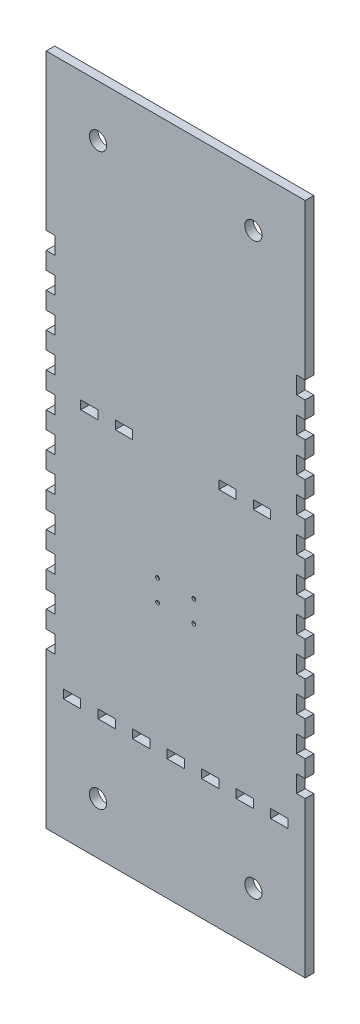
from build123d import *

# Parameters (mm, degrees)
CROQUIS1_W              = 150
CROQUIS1_H              = 390
CROQUIS1_R              = 5
SALIENTE_EXTRUIR1_DEPTH = 5
CROQUIS3_W              = 5
CROQUIS3_H              = 10
CROQUIS3_W_2            = 10
CROQUIS3_H_2            = 5
CORTAR_EXTRUIR1_DEPTH   = 10
CROQUIS4_W              = 10
CROQUIS4_H              = 5
CORTAR_EXTRUIR2_DEPTH   = 10
CROQUIS6_R              = 1.1
CORTAR_EXTRUIR7_DEPTH   = 1


with BuildPart() as part:
    # Croquis1 → Saliente-Extruir1 (new body)
    with BuildSketch(Plane.XY):
        Rectangle(CROQUIS1_W, CROQUIS1_H)
        with Locations((-45, 165)):
            Circle(CROQUIS1_R, mode=Mode.SUBTRACT)
        with Locations((45, 165)):
            Circle(CROQUIS1_R, mode=Mode.SUBTRACT)
        with Locations((-45, -165)):
            Circle(CROQUIS1_R, mode=Mode.SUBTRACT)
        with Locations((45, -165)):
            Circle(CROQUIS1_R, mode=Mode.SUBTRACT)
    extrude(amount=SALIENTE_EXTRUIR1_DEPTH)

    # Croquis3 → Cortar-Extruir1 (cut)
    with BuildSketch(Plane(origin=(0, 0, 0), x_dir=(-1, 0, 0), z_dir=(0, 0, -1))):
        with Locations((-72.5, 100)):
            Rectangle(CROQUIS3_W, CROQUIS3_H)
        with Locations((-72.5, 80)):
            Rectangle(CROQUIS3_W, CROQUIS3_H)
        with Locations((-72.5, 60)):
            Rectangle(CROQUIS3_W, CROQUIS3_H)
        with Locations((-72.5, 40)):
            Rectangle(CROQUIS3_W, CROQUIS3_H)
        with Locations((-72.5, 20)):
            Rectangle(CROQUIS3_W, CROQUIS3_H)
        with Locations((-72.5, 0)):
            Rectangle(CROQUIS3_W, CROQUIS3_H)
        with Locations((-72.5, -20)):
            Rectangle(CROQUIS3_W, CROQUIS3_H)
        with Locations((-72.5, -40)):
            Rectangle(CROQUIS3_W, CROQUIS3_H)
        with Locations((-72.5, -60)):
            Rectangle(CROQUIS3_W, CROQUIS3_H)
        with Locations((-72.5, -80)):
            Rectangle(CROQUIS3_W, CROQUIS3_H)
        with Locations((-72.5, -100)):
            Rectangle(CROQUIS3_W, CROQUIS3_H)
        with Locations((72.5, -100)):
            Rectangle(CROQUIS3_W, CROQUIS3_H)
        with Locations((72.5, -80)):
            Rectangle(CROQUIS3_W, CROQUIS3_H)
        with Locations((72.5, -60)):
            Rectangle(CROQUIS3_W, CROQUIS3_H)
        with Locations((72.5, -40)):
            Rectangle(CROQUIS3_W, CROQUIS3_H)
        with Locations((72.5, -20)):
            Rectangle(CROQUIS3_W, CROQUIS3_H)
        with Locations((72.5, 0)):
            Rectangle(CROQUIS3_W, CROQUIS3_H)
        with Locations((72.5, 20)):
            Rectangle(CROQUIS3_W, CROQUIS3_H)
        with Locations((72.5, 40)):
            Rectangle(CROQUIS3_W, CROQUIS3_H)
        with Locations((72.5, 60)):
            Rectangle(CROQUIS3_W, CROQUIS3_H)
        with Locations((72.5, 80)):
            Rectangle(CROQUIS3_W, CROQUIS3_H)
        with Locations((72.5, 100)):
            Rectangle(CROQUIS3_W, CROQUIS3_H)
        with Locations((-40, -122.5)):
            Rectangle(CROQUIS3_W_2, CROQUIS3_H_2)
        with Locations((-60, -122.5)):
            Rectangle(CROQUIS3_W_2, CROQUIS3_H_2)
        with Locations((-20, -122.5)):
            Rectangle(CROQUIS3_W_2, CROQUIS3_H_2)
        with Locations((0, -122.5)):
            Rectangle(CROQUIS3_W_2, CROQUIS3_H_2)
        with Locations((20, -122.5)):
            Rectangle(CROQUIS3_W_2, CROQUIS3_H_2)
        with Locations((40, -122.5)):
            Rectangle(CROQUIS3_W_2, CROQUIS3_H_2)
        with Locations((60, -122.5)):
            Rectangle(CROQUIS3_W_2, CROQUIS3_H_2)
    extrude(amount=-CORTAR_EXTRUIR1_DEPTH, mode=Mode.SUBTRACT)

    # Croquis4 → Cortar-Extruir2 (cut)
    with BuildSketch(Plane(origin=(0, 0, 0), x_dir=(-1, 0, 0), z_dir=(0, 0, -1))):
        with Locations((-50, 27.5)):
            Rectangle(CROQUIS4_W, CROQUIS4_H)
        with Locations((-30, 27.5)):
            Rectangle(CROQUIS4_W, CROQUIS4_H)
        with Locations((30, 27.5)):
            Rectangle(CROQUIS4_W, CROQUIS4_H)
        with Locations((50, 27.5)):
            Rectangle(CROQUIS4_W, CROQUIS4_H)
    extrude(amount=-CORTAR_EXTRUIR2_DEPTH, mode=Mode.SUBTRACT)

    # Croquis6 → Cortar-Extruir7 (cut)
    with BuildSketch(Plane.XY.offset(5)):
        with Locations((-10.5, -37)):
            Circle(CROQUIS6_R)
        with Locations((10.5, -37)):
            Circle(CROQUIS6_R)
        with Locations((10.5, -49.5)):
            Circle(CROQUIS6_R)
        with Locations((-10.5, -49.5)):
            Circle(CROQUIS6_R)
    extrude(amount=-CORTAR_EXTRUIR7_DEPTH, mode=Mode.SUBTRACT)


solid = part.part
